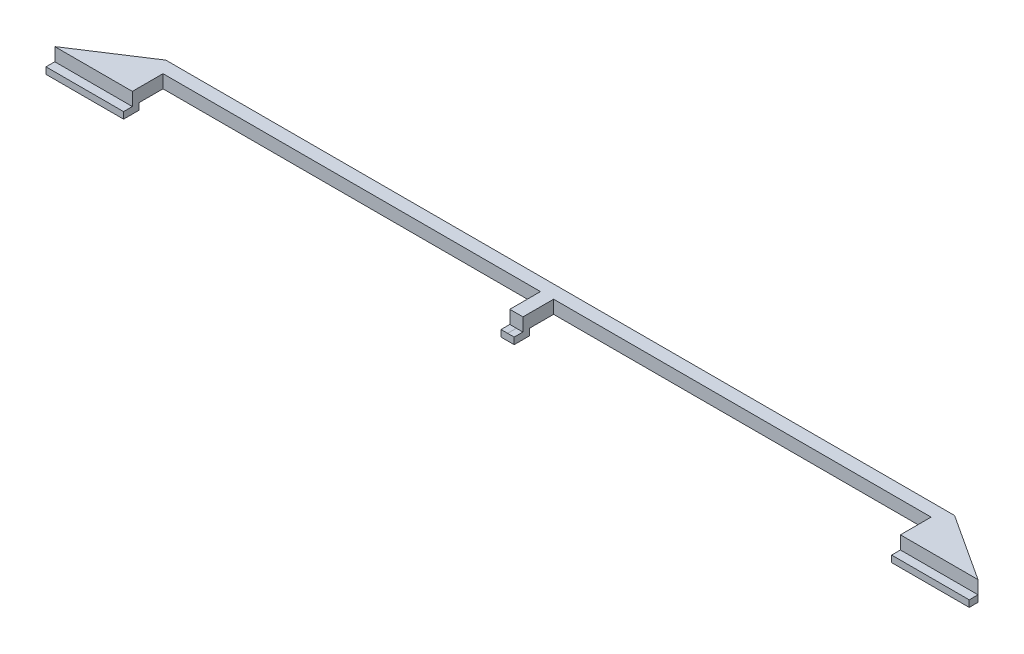
from build123d import *

# Parameters (mm, degrees)
SKETCH1_W           = 900
SKETCH1_H           = 30
BOSS_EXTRUDE1_DEPTH = 30
SKETCH2_W           = 15
SKETCH2_H           = 100
BOSS_EXTRUDE2_DEPTH = 30
SKETCH3_W           = 15
SKETCH3_H           = 15
BOSS_EXTRUDE3_DEPTH = 15
SKETCH4_W           = 177.04771777
SKETCH4_H           = 15
BOSS_EXTRUDE4_DEPTH = 20
SKETCH5_W           = 2368.555450384
SKETCH5_H           = 727.009925826
CUT_EXTRUDE1_DEPTH  = 45


with BuildPart() as part:
    # Sketch1 → Boss-Extrude1 (new body)
    with BuildSketch(Plane(origin=(0, 0, 0), x_dir=(1, 0, 0), z_dir=(0, 1, 0))):
        Rectangle(SKETCH1_W, SKETCH1_H)
    extrude(amount=BOSS_EXTRUDE1_DEPTH)

    # Sketch2 → Boss-Extrude2 (add)
    with BuildSketch(Plane(origin=(0, 30, 0), x_dir=(1, 0, 0), z_dir=(0, 1, 0))):
        Polygon((-450, 15), (-603.496801426, -85), (-426.449083656, -85), (-426.449083656, 15), align=None)
        with Locations((442.5, -35)):
            Rectangle(SKETCH2_W, SKETCH2_H)
    extrude(amount=-BOSS_EXTRUDE2_DEPTH)

    # Sketch3 → Boss-Extrude3 (add)
    with BuildSketch(Plane(origin=(0, 30, 0), x_dir=(1, 0, 0), z_dir=(0, 1, 0))):
        Polygon((-603.496801426, -85), (-580.472281212, -70), (-426.449083656, -70), (-426.449083656, -85), align=None)
        with Locations((442.5, -77.5)):
            Rectangle(SKETCH3_W, SKETCH3_H)
    extrude(amount=BOSS_EXTRUDE3_DEPTH)

    # Sketch4 → Boss-Extrude4 (add)
    with BuildSketch(Plane.XY.offset(85)):
        with Locations((-514.972942541, 37.5)):
            Rectangle(SKETCH4_W, SKETCH4_H)
        Polygon((435, 45), (450, 45), (450, 30), (435, 29.894509732), align=None)
    extrude(amount=BOSS_EXTRUDE4_DEPTH)

    # Mirror1: part across plane


with BuildPart() as part_1:
    add(part.part)
    add(part.part.mirror(Plane(origin=(450, 30, -15), x_dir=(0, 0, 1), z_dir=(-1, 0, 0))))


with BuildPart() as body_2:
    # Mirror3: mirrored copy
    add(part_1.part.mirror(Plane(origin=(1412.655320372, 45, 87.858325649), x_dir=(0, 0, 1), z_dir=(0, 1, 0))))


with BuildPart() as part_2:
    add(part_1.part)

    # Sketch5 → Cut-Extrude1 (cut)
    with BuildSketch(Plane(origin=(0, 0, 0), x_dir=(-1, 0, 0), z_dir=(0, -1, 0))):
        with Locations((-465, -50)):
            Rectangle(SKETCH5_W, SKETCH5_H)
    extrude(amount=-CUT_EXTRUDE1_DEPTH, mode=Mode.SUBTRACT)


solid = body_2.part
